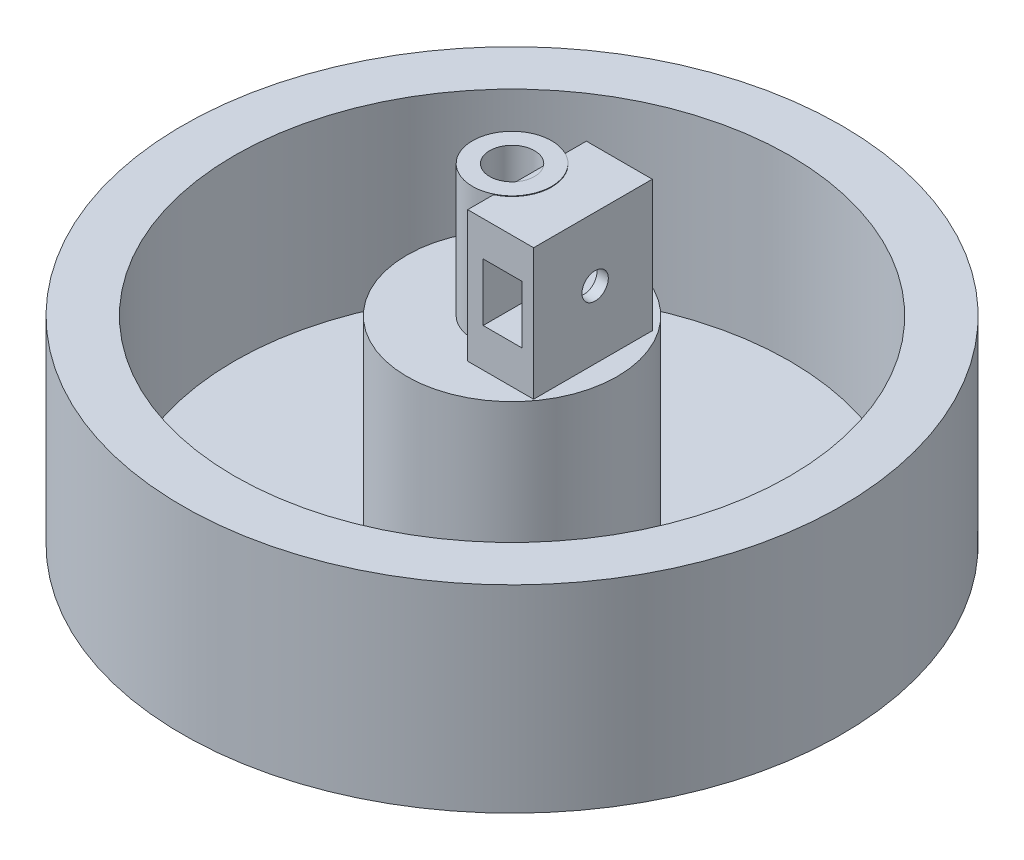
from build123d import *

# Parameters (mm, degrees)
SKETCH1_R               = 6
BOSS_EXTRUDE1_DEPTH     = 20
SKETCH2_R               = 3.4
CUT_EXTRUDE1_DEPTH      = 13.55
SKETCH5_W               = 1.550685087
SKETCH5_H               = 7.184215806
BOSS_EXTRUDE2_DEPTH     = 13.55
SKETCH7_W               = 18.003976239
SKETCH7_H               = 19.909960041
BOSS_EXTRUDE3_DEPTH     = 10
CUT_EXTRUDE2_DEPTH      = 1
CUT_EXTRUDE2_DEPTH_BACK = 13.55
SKETCH6_R               = 2
CUT_EXTRUDE3_DEPTH      = 10
CUT_EXTRUDE3_DEPTH_BACK = 10
SKETCH10_R              = 50
BOSS_EXTRUDE4_DEPTH     = 30
SKETCH12_R              = 42.124366513
SKETCH12_R_2            = 15.95790089
CUT_EXTRUDE5_DEPTH      = 27


with BuildPart() as part:
    # Sketch1 → Boss-Extrude1 (new body)
    with BuildSketch(Plane(origin=(0, 0, 0), x_dir=(1, 0, 0), z_dir=(0, 1, 0))):
        Circle(SKETCH1_R)
    extrude(amount=BOSS_EXTRUDE1_DEPTH)

    # Sketch2 → Cut-Extrude1 (cut)
    with BuildSketch(Plane(origin=(0, 20, 0), x_dir=(1, 0, 0), z_dir=(0, 1, 0))):
        Circle(SKETCH2_R)
    extrude(amount=-CUT_EXTRUDE1_DEPTH, mode=Mode.SUBTRACT)

    # Sketch5 → Boss-Extrude2 (add)
    with BuildSketch(Plane(origin=(0, 18.26, 0), x_dir=(1, 0, 0), z_dir=(0, 1, 0))):
        with Locations((3.375342544, 0.020519704)):
            Rectangle(SKETCH5_W, SKETCH5_H)
    extrude(amount=-BOSS_EXTRUDE2_DEPTH)

    # Sketch7 → Boss-Extrude3 (add)
    with BuildSketch(Plane.ZY.offset(-2.6)):
        with Locations((0.33027221, 9.954980021)):
            Rectangle(SKETCH7_W, SKETCH7_H)
    extrude(amount=-BOSS_EXTRUDE3_DEPTH)

    # Sketch6 → Cut-Extrude2 (cut, two sides: drawn at the far end of the back side and taken through both)
    with BuildSketch(Plane.ZY.offset(-2.6).offset(-CUT_EXTRUDE2_DEPTH_BACK)):
        with Locations((0, 10.236925537)):
            Circle(SKETCH6_R)
    extrude(amount=CUT_EXTRUDE2_DEPTH + CUT_EXTRUDE2_DEPTH_BACK, mode=Mode.SUBTRACT)

    # Sketch9 → Cut-Extrude3 (cut, two sides: drawn at the far end of the back side and taken through both)
    with BuildSketch(Plane.XY.offset(-CUT_EXTRUDE3_DEPTH_BACK)):
        Polygon((10.876516382, 10.236925537), (10.876516382, 5.861925537), (4.943430227, 5.861925537), (4.943430227, 10.236925537), (4.943430227, 14.614332445), (10.876516382, 14.614332445), align=None)
    extrude(amount=CUT_EXTRUDE3_DEPTH + CUT_EXTRUDE3_DEPTH_BACK, mode=Mode.SUBTRACT)

    # Sketch10 → Boss-Extrude4 (add)
    with BuildSketch(Plane.XZ):
        Circle(SKETCH10_R)
    extrude(amount=BOSS_EXTRUDE4_DEPTH)

    # Sketch12 → Cut-Extrude5 (cut)
    with BuildSketch(Plane(origin=(0, 0, 0), x_dir=(1, 0, 0), z_dir=(0, 1, 0))):
        Circle(SKETCH12_R)
        Circle(SKETCH12_R_2, mode=Mode.SUBTRACT)
    extrude(amount=-CUT_EXTRUDE5_DEPTH, mode=Mode.SUBTRACT)


solid = part.part
